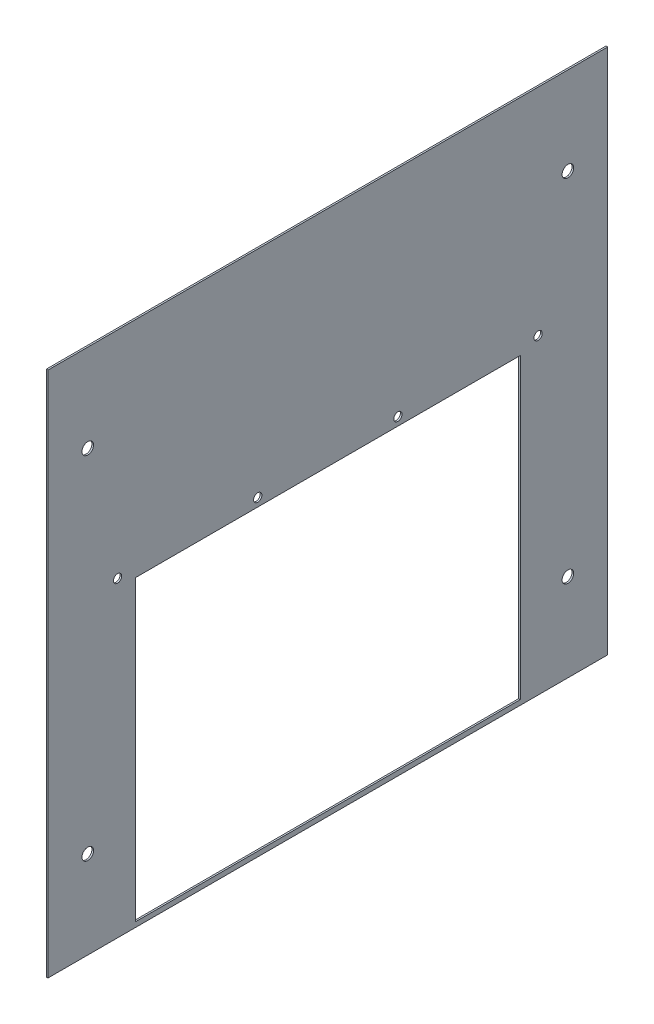
from build123d import *

# Parameters (mm, degrees)
SKETCH1_W           = 338
SKETCH1_H           = 318
SKETCH1_R           = 3.5
BOSS_EXTRUDE1_DEPTH = 1
SKETCH2_R           = 2.5
SKETCH2_W           = 232.5
SKETCH2_H           = 180
CUT_EXTRUDE1_DEPTH  = 2


with BuildPart() as part:
    # Sketch1 → Boss-Extrude1 (new body)
    with BuildSketch(Plane(origin=(0, 0, 0), x_dir=(0, 0, -1), z_dir=(1, 0, 0))):
        with Locations((169, 159)):
            Rectangle(SKETCH1_W, SKETCH1_H)
        with Locations((24, 265.06)):
            Circle(SKETCH1_R, mode=Mode.SUBTRACT)
        with Locations((314, 265.06)):
            Circle(SKETCH1_R, mode=Mode.SUBTRACT)
        with Locations((314, 52.94)):
            Circle(SKETCH1_R, mode=Mode.SUBTRACT)
        with Locations((24, 52.94)):
            Circle(SKETCH1_R, mode=Mode.SUBTRACT)
    extrude(amount=BOSS_EXTRUDE1_DEPTH)

    # Sketch2 → Cut-Extrude1 (cut, through all)
    with BuildSketch(Plane.ZY):
        with Locations((-296, 188)):
            Circle(SKETCH2_R)
        with Locations((-211.333333333, 188)):
            Circle(SKETCH2_R)
        with Locations((-126.666666667, 188)):
            Circle(SKETCH2_R)
        with Locations((-42, 188)):
            Circle(SKETCH2_R)
        with Locations((-169, 93)):
            Rectangle(SKETCH2_W, SKETCH2_H)
    extrude(amount=-CUT_EXTRUDE1_DEPTH, mode=Mode.SUBTRACT)


solid = part.part
